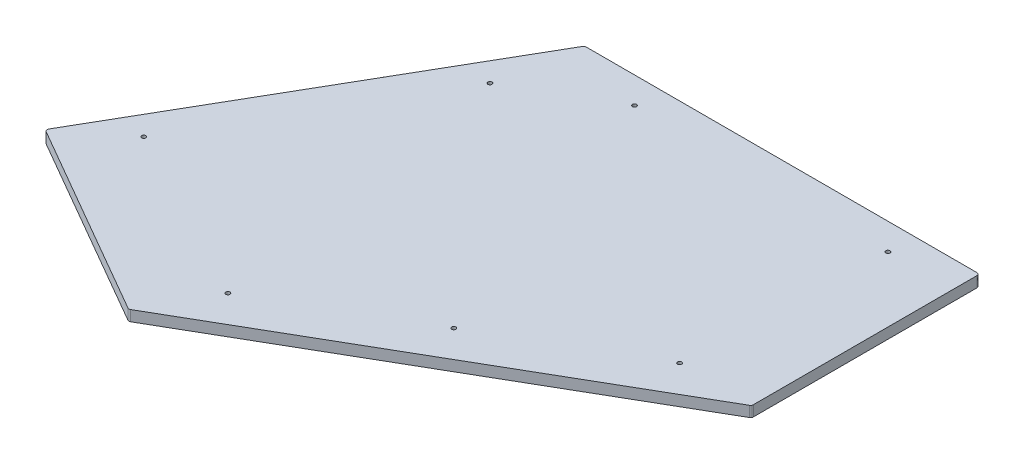
from build123d import *

# Parameters (mm, degrees)
SKETCH1_R           = 2.45745
BOSS_EXTRUDE1_DEPTH = 12.7
FILLET1_R           = 3.175


with BuildPart() as part:
    # Sketch1 → Boss-Extrude1 (new body)
    with BuildSketch(Plane(origin=(0, 0, 0), x_dir=(1, 0, 0), z_dir=(0, 1, 0))):
        Polygon((-0.199185023, -544.98942083), (472.075100704, -272.319932268), (472.075100704, -189.70625), (472.075100704, -89.69375), (472.075100704, 0), (0, 0), (-236.036311861, -408.829744745), (-159.04651881, -453.279511515), (-71.058183894, -504.079244967), align=None)
        with Locations((-169.646411276, -357.338592529)):
            Circle(SKETCH1_R, mode=Mode.SUBTRACT)
        with Locations((-18.164146109, -94.961777227)):
            Circle(SKETCH1_R, mode=Mode.SUBTRACT)
        with Locations((91.321480704, -31.749605568)):
            Circle(SKETCH1_R, mode=Mode.SUBTRACT)
        with Locations((394.287600704, -31.749605568)):
            Circle(SKETCH1_R, mode=Mode.SUBTRACT)
        with Locations((384.876900704, -271.337645568)):
            Circle(SKETCH1_R, mode=Mode.SUBTRACT)
        with Locations((213.713214706, -370.159699049)):
            Circle(SKETCH1_R, mode=Mode.SUBTRACT)
        with Locations((42.549528708, -468.981752529)):
            Circle(SKETCH1_R, mode=Mode.SUBTRACT)
    extrude(amount=BOSS_EXTRUDE1_DEPTH)

    # Fillet1
    fillet1_edges = [part.edges().sort_by_distance(p)[0] for p in [
        (472.075100704, 6.35, 272.319932268),
        (-0.199185023, 6.35, 544.98942083),
        (-236.036311861, 6.35, 408.829744745),
        (0, 6.35, 0),
        (472.075100704, 6.35, 0),
    ]]
    fillet(fillet1_edges, radius=FILLET1_R)


solid = part.part
